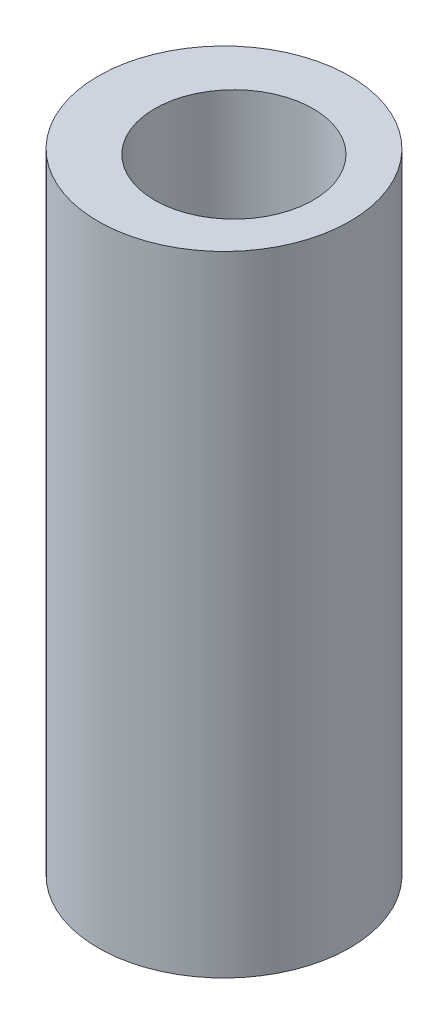
from build123d import *

# Parameters (mm, degrees)
SKETCH1_W = 6.35
SKETCH1_H = 31.75


with BuildPart() as part:
    # Sketch1 → Revolve1 (revolve)
    with BuildSketch(Plane.XY):
        with Locations((3.175, 0)):
            Rectangle(SKETCH1_W, SKETCH1_H)
    revolve(axis=Axis((0, 7.563970588, 0), (0, -1, 0)))

    # Sketch2 → Cut-Revolve3 (revolve, cut)
    with BuildSketch(Plane.XY):
        Polygon((4.5, 15.875), (4.5, 9.875), (3.5, 9.875), (3.5, -9.875), (4.5, -9.875), (4.5, -15.875), (0.5, -15.875), (0.5, 15.875), align=None)
    revolve(axis=Axis((0.5, -7.982322113, 0), (0, -1, 0)), mode=Mode.SUBTRACT)


solid = part.part
